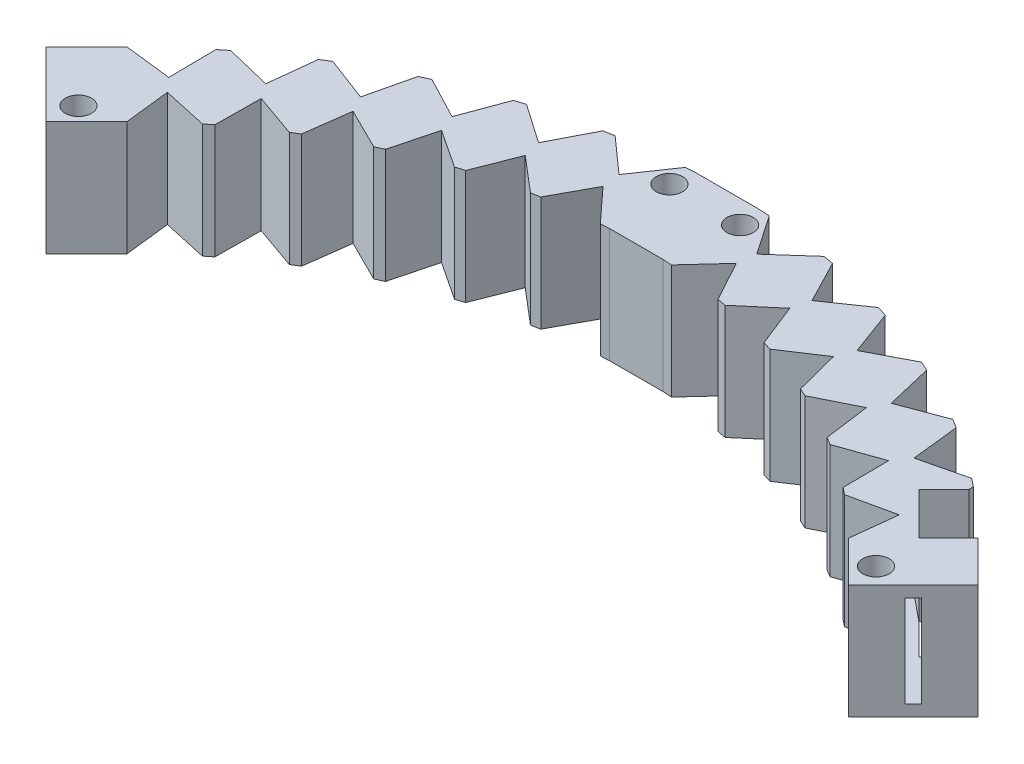
from build123d import *

# Parameters (mm, degrees)
BOSS_EXTRUDE1_DEPTH = 10
CUT_EXTRUDE1_DEPTH  = 10
CIRPATTERN1_COUNT   = 13
CIRPATTERN1_ANGLE   = 84
CUT_EXTRUDE2_START  = -1
CUT_EXTRUDE2_DEPTH  = 8
SKETCH5_W           = 8
SKETCH5_H           = 10
SKETCH5_W_2         = 0.983564582
SKETCH5_H_2         = 7.885827621
BOSS_EXTRUDE2_DEPTH = 5
SKETCH6_W           = 8
SKETCH6_H           = 10
SKETCH6_W_2         = 1
SKETCH6_H_2         = 8
BOSS_EXTRUDE3_DEPTH = 5
SKETCH7_R           = 1.15
CUT_EXTRUDE3_DEPTH  = 20
SKETCH9_R           = 1.15
CUT_EXTRUDE4_DEPTH  = 26
SKETCH10_R          = 1.15
CUT_EXTRUDE5_DEPTH  = 26
BOSS_EXTRUDE4_DEPTH = 10
CUT_EXTRUDE7_DEPTH  = 26


with BuildPart() as part:
    # Sketch1 → Boss-Extrude1 (new body)
    with BuildSketch(Plane(origin=(0, 0, 0), x_dir=(1, 0, 0), z_dir=(0, 1, 0))):
        with BuildLine():
            Line((-31.50867817, 31.50867817), (-37.165532419, 37.165532419))
            ThreePointArc((-37.165532419, 37.165532419), (0, 52.56), (37.165532419, 37.165532419))
            Line((37.165532419, 37.165532419), (31.50867817, 31.50867817))
            ThreePointArc((31.50867817, 31.50867817), (0, 44.56), (-31.50867817, 31.50867817))
        make_face()
    extrude(amount=BOSS_EXTRUDE1_DEPTH)

    # Sketch3 → Cut-Extrude1 (cut)
    with BuildSketch(Plane(origin=(0, 10, 0), x_dir=(1, 0, 0), z_dir=(0, 1, 0))):
        with BuildLine():
            Line((-31.95767776, 35.492596865), (-31.50867817, 31.50867817))
            ThreePointArc((-31.50867817, 31.50867817), (-29.816459819, 33.114533423), (-28.042516625, 34.629624043))
            Line((-28.042516625, 34.629624043), (-31.95767776, 35.492596865))
        make_face()
        with BuildLine():
            Line((-33.02828673, 36.681628586), (-33.077079754, 40.846791734))
            ThreePointArc((-33.077079754, 40.846791734), (-35.16950467, 39.059692027), (-37.165532419, 37.165532419))
            Line((-37.165532419, 37.165532419), (-33.02828673, 36.681628586))
        make_face()
    cut_extrude1 = extrude(amount=-CUT_EXTRUDE1_DEPTH, mode=Mode.SUBTRACT)

    # CirPattern1: Cut-Extrude1 ×13 about axis
    cirpattern1_axis = Axis((0, 0, 0), (0, -1, 0))
    for i in range(1, CIRPATTERN1_COUNT):
        add(cut_extrude1.rotate(cirpattern1_axis, i * CIRPATTERN1_ANGLE / (CIRPATTERN1_COUNT - 1)), mode=Mode.SUBTRACT)

    # Sketch4 → Cut-Extrude2 (cut)
    with BuildSketch(Plane(origin=(0, 10, 0), x_dir=(1, 0, 0), z_dir=(0, 1, 0)).offset(CUT_EXTRUDE2_START)):
        with BuildLine():
            Line((33.983551904, 33.983551904), (34.690658685, 34.690658685))
            ThreePointArc((34.690658685, 34.690658685), (0, 49.06), (-34.690658685, 34.690658685))
            Line((-34.690658685, 34.690658685), (-33.983551904, 33.983551904))
            ThreePointArc((-33.983551904, 33.983551904), (0, 48.06), (33.983551904, 33.983551904))
        make_face()
    extrude(amount=-CUT_EXTRUDE2_DEPTH, mode=Mode.SUBTRACT)

    # Sketch5 → Boss-Extrude2 (add)
    with BuildSketch(Plane(origin=(0, 0, 0), x_dir=(0.707106781, 0, 0.707106781), z_dir=(-0.707106781, 0, 0.707106781))):
        with Locations((-48.56, 5)):
            Rectangle(SKETCH5_W, SKETCH5_H)
        with Locations((-48.568217709, 5.057086189)):
            Rectangle(SKETCH5_W_2, SKETCH5_H_2, mode=Mode.SUBTRACT)
    extrude(amount=BOSS_EXTRUDE2_DEPTH)

    # Sketch6 → Boss-Extrude3 (add)
    with BuildSketch(Plane(origin=(0, 0, 0), x_dir=(0.707106781, 0, -0.707106781), z_dir=(0.707106781, 0, 0.707106781))):
        with Locations((48.56, 5)):
            Rectangle(SKETCH6_W, SKETCH6_H)
        with Locations((48.56, 5)):
            Rectangle(SKETCH6_W_2, SKETCH6_H_2, mode=Mode.SUBTRACT)
    extrude(amount=BOSS_EXTRUDE3_DEPTH)

    # Sketch7 → Cut-Extrude3 (cut)
    with BuildSketch(Plane(origin=(0, 10, 0), x_dir=(1, 0, 0), z_dir=(0, 1, 0))):
        with Locations((-3.086614159, 50.465695408)):
            Circle(SKETCH7_R)
        with Locations((3.086614159, 50.465695408)):
            Circle(SKETCH7_R)
    extrude(amount=-CUT_EXTRUDE3_DEPTH, mode=Mode.SUBTRACT)

    # Sketch9 → Cut-Extrude4 (cut)
    with BuildSketch(Plane(origin=(0, 10, 0), x_dir=(1, 0, 0), z_dir=(0, 1, 0))):
        with Locations((34.832080041, 30.589439354)):
            Circle(SKETCH9_R)
    extrude(amount=-CUT_EXTRUDE4_DEPTH, mode=Mode.SUBTRACT)

    # Sketch10 → Cut-Extrude5 (cut)
    with BuildSketch(Plane(origin=(0, 10, 0), x_dir=(1, 0, 0), z_dir=(0, 1, 0))):
        with Locations((-34.832080041, 30.589439354)):
            Circle(SKETCH10_R)
    extrude(amount=-CUT_EXTRUDE5_DEPTH, mode=Mode.SUBTRACT)

    # Sketch11 → Boss-Extrude4 (add)
    with BuildSketch(Plane(origin=(0, 10, 0), x_dir=(1, 0, 0), z_dir=(0, 1, 0))):
        Polygon((-2.75077786, 52.487968347), (2.75077786, 52.487968347), (0, 49.36), align=None)
        Polygon((0, 47.76), (-2.33209021, 44.498932069), (2.33209021, 44.498932069), align=None)
    extrude(amount=-BOSS_EXTRUDE4_DEPTH)

    # Sketch14 → Cut-Extrude7 (cut)
    with BuildSketch(Plane(origin=(0, 10, 0), x_dir=(1, 0, 0), z_dir=(0, 1, 0))):
        Polygon((37.165532419, 37.165532419), (34.594853292, 34.594853292), (30.896603346, 38.293103238), (33.467282473, 40.863782365), align=None)
    extrude(amount=-CUT_EXTRUDE7_DEPTH, mode=Mode.SUBTRACT)


solid = part.part
